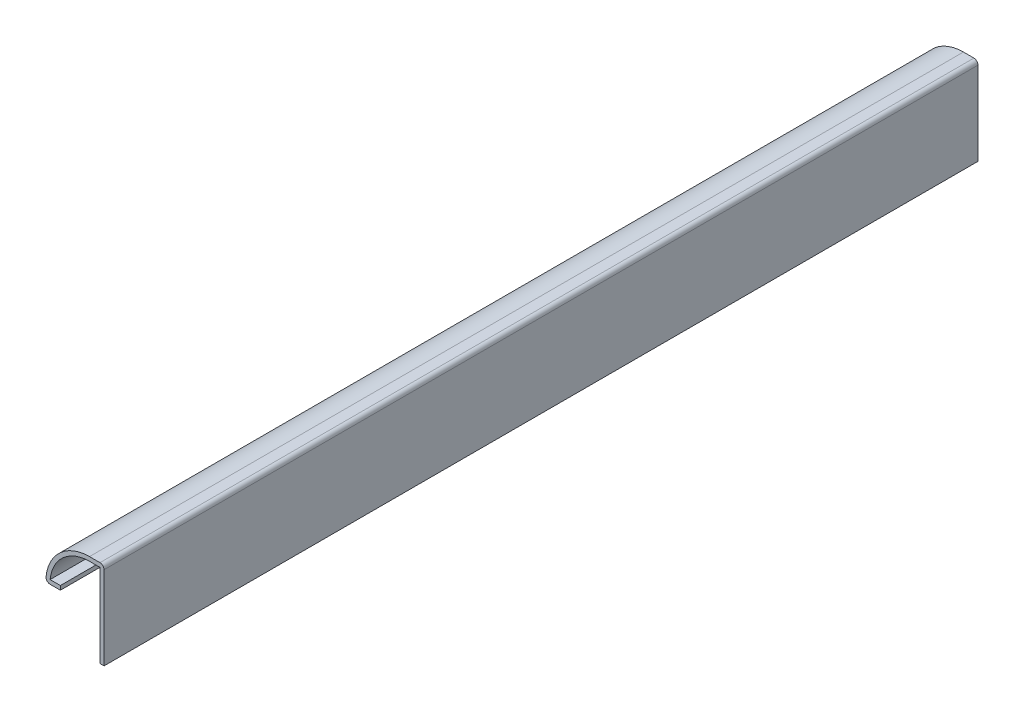
from build123d import *

# Parameters (mm, degrees)
EXTRUDE_THIN1_DEPTH = 190.5
FILLET1_R           = 0.889


with BuildPart() as part:
    # Sketch1 → Extrude-Thin1 (new body)
    with BuildSketch(Plane.XY):
        with BuildLine():
            Line((0, 0), (0, 19.05))
            Line((0, 19.05), (-3.175, 19.05))
            ThreePointArc((-3.175, 19.05), (-9.910192091, 16.260192091), (-12.7, 9.525))
            Line((-12.7, 9.525), (-9.525, 9.525))
            Line((-9.525, 9.525), (-9.525, 10.414))
            Line((-9.525, 10.414), (-11.765120779, 10.414))
            ThreePointArc((-11.765120779, 10.414), (-8.958731149, 15.938185636), (-3.175, 18.161))
            Line((-3.175, 18.161), (-0.889, 18.161))
            Line((-0.889, 18.161), (-0.889, 0))
            Line((-0.889, 0), (0, 0))
        make_face()
    extrude(amount=-EXTRUDE_THIN1_DEPTH)

    # Fillet1
    fillet1_edges = [part.edges().sort_by_distance(p)[0] for p in [
        (-12.7, 9.525, -95.25),
        (0, 19.05, -95.25),
    ]]
    fillet(fillet1_edges, radius=FILLET1_R)


solid = part.part
